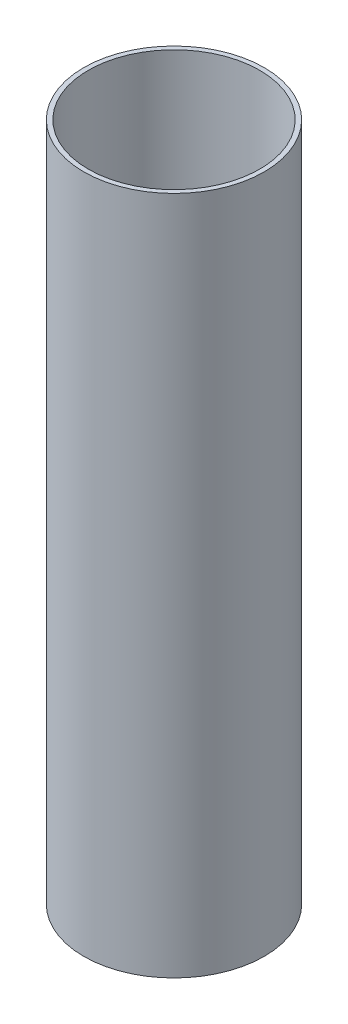
from build123d import *

# Parameters (mm, degrees)
SKETCH1_R           = 93.6625
SKETCH1_R_2         = 88.9
BOSS_EXTRUDE1_DEPTH = 352.425


with BuildPart() as part:
    # Sketch1 → Boss-Extrude1 (new body, symmetric)
    with BuildSketch(Plane(origin=(0, 0, 0), x_dir=(1, 0, 0), z_dir=(0, 1, 0))):
        Circle(SKETCH1_R)
        Circle(SKETCH1_R_2, mode=Mode.SUBTRACT)
    extrude(amount=BOSS_EXTRUDE1_DEPTH, both=True)


solid = part.part
